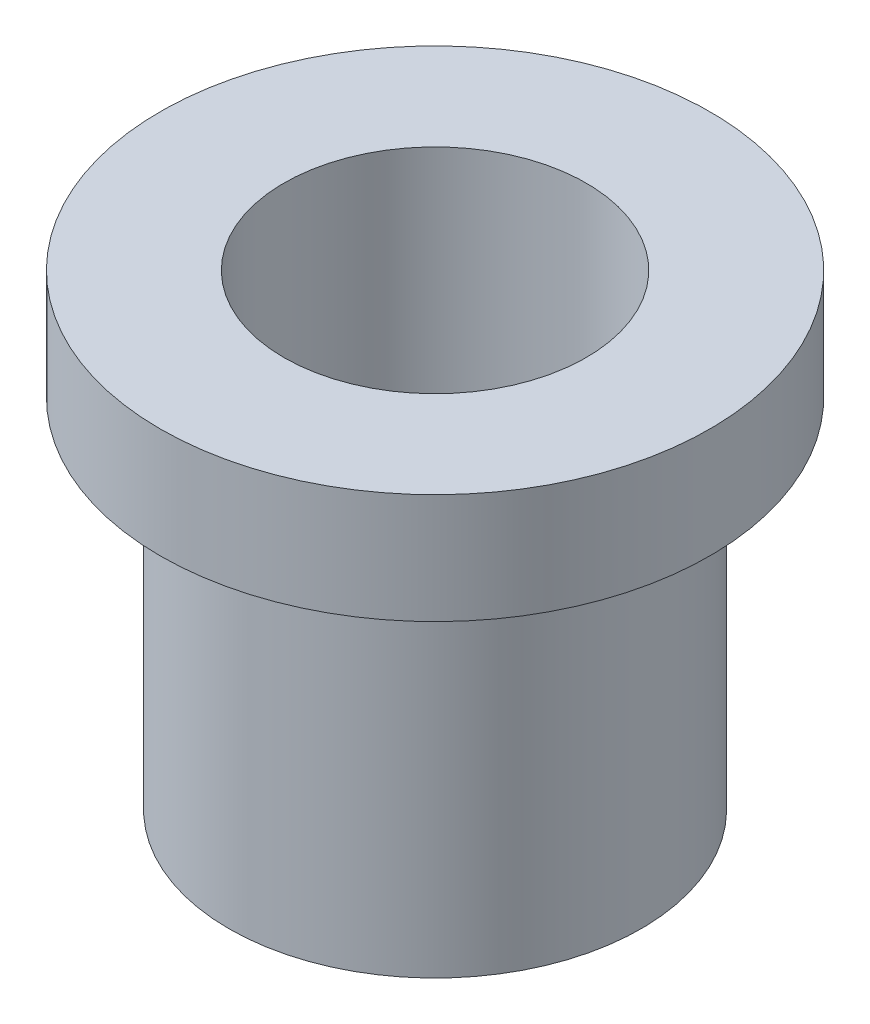
from build123d import *

# Parameters (mm, degrees)
SKETCH2_R           = 3.75
BOSS_EXTRUDE1_DEPTH = 6.5
SKETCH3_R           = 5
BOSS_EXTRUDE2_DEPTH = 2
SKETCH4_R           = 1.25
CUT_EXTRUDE1_DEPTH  = 6.5
SKETCH5_R           = 2.75
CUT_EXTRUDE2_DEPTH  = 5


with BuildPart() as part:
    # Sketch2 → Boss-Extrude1 (new body)
    with BuildSketch(Plane(origin=(0, 0, 0), x_dir=(1, 0, 0), z_dir=(0, 1, 0))):
        Circle(SKETCH2_R)
    extrude(amount=BOSS_EXTRUDE1_DEPTH)

    # Sketch3 → Boss-Extrude2 (add)
    with BuildSketch(Plane(origin=(0, 6.5, 0), x_dir=(1, 0, 0), z_dir=(0, 1, 0))):
        Circle(SKETCH3_R)
    extrude(amount=BOSS_EXTRUDE2_DEPTH)

    # Sketch4 → Cut-Extrude1 (cut)
    with BuildSketch(Plane.XZ):
        Circle(SKETCH4_R)
    extrude(amount=-CUT_EXTRUDE1_DEPTH, mode=Mode.SUBTRACT)

    # Sketch5 → Cut-Extrude2 (cut)
    with BuildSketch(Plane(origin=(0, 8.5, 0), x_dir=(1, 0, 0), z_dir=(0, 1, 0))):
        Circle(SKETCH5_R)
    extrude(amount=-CUT_EXTRUDE2_DEPTH, mode=Mode.SUBTRACT)


solid = part.part
